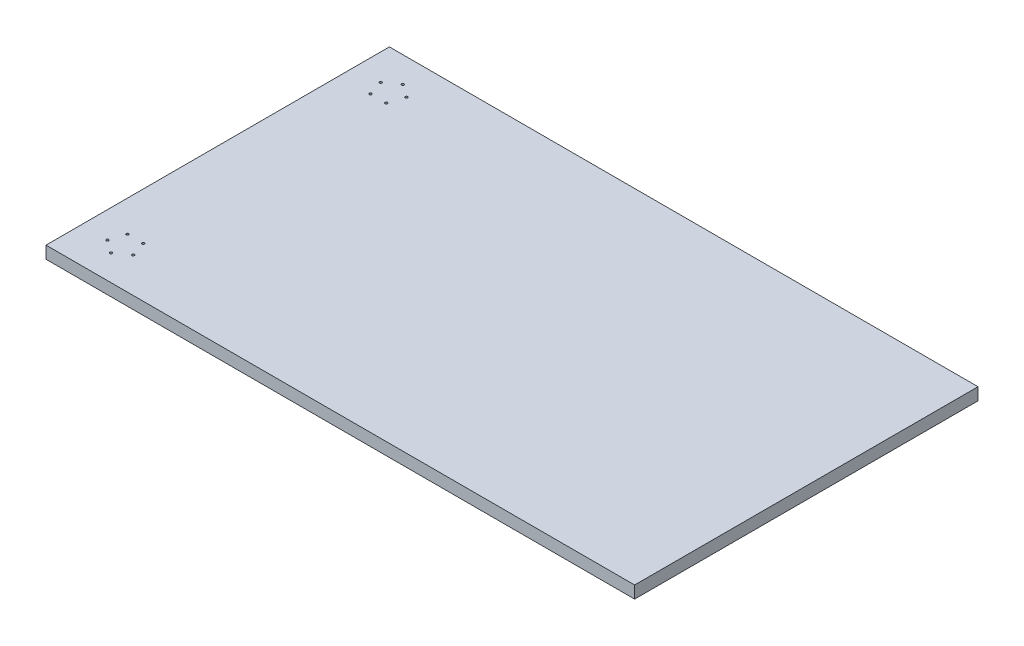
from build123d import *

# Parameters (mm, degrees)
SKETCH1_W                   = 1200
SKETCH1_H                   = 700
BOSS_EXTRUDE1_DEPTH         = 25
TAP_DRILL_FOR_M6_TAP1_D     = 5
TAP_DRILL_FOR_M6_TAP1_DEPTH = 15
TAP_DRILL_FOR_M6_TAP1_TIP   = 1.502151548


with BuildPart() as part:
    # Sketch1 → Boss-Extrude1 (new body)
    with BuildSketch(Plane(origin=(0, 0, 0), x_dir=(1, 0, 0), z_dir=(0, 1, 0))):
        Rectangle(SKETCH1_W, SKETCH1_H)
    extrude(amount=BOSS_EXTRUDE1_DEPTH)

    # Tap Drill for M6 Tap1
    with Locations(Plane(origin=(-493.845945802, 25, -278.497967345), x_dir=(0, 0, 1), z_dir=(0, 1, 0))):
        with Locations((0, 0), (-19.002032655, -26.154054198), (0, -52.308108396), (30.74593469, -42.318148636), (30.74593469, -9.98995976), (556.99593469, 0), (526.25, -9.98995976), (526.25, -42.318148636), (556.99593469, -52.308108396), (575.997967345, -26.154054198)):
            Hole(TAP_DRILL_FOR_M6_TAP1_D / 2, depth=TAP_DRILL_FOR_M6_TAP1_DEPTH)
            with Locations((0, 0, -(TAP_DRILL_FOR_M6_TAP1_DEPTH + TAP_DRILL_FOR_M6_TAP1_TIP / 2))):  # 118° drill point
                Cone(0, TAP_DRILL_FOR_M6_TAP1_D / 2, TAP_DRILL_FOR_M6_TAP1_TIP, mode=Mode.SUBTRACT)


solid = part.part
